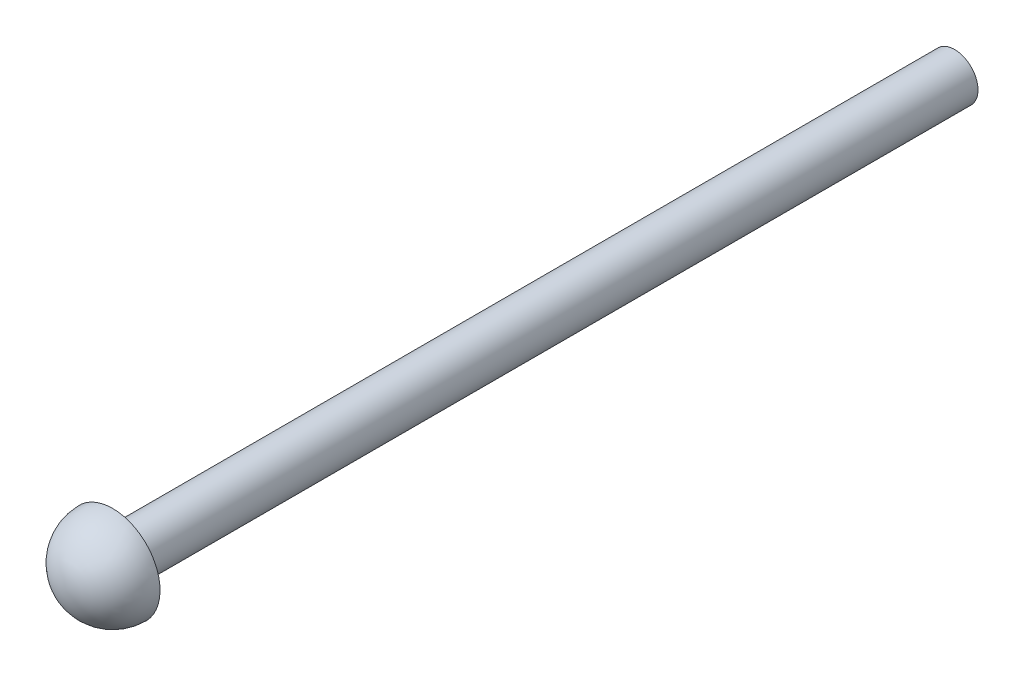
from build123d import *

# Parameters (mm, degrees)
SKETCH1_R           = 3.175
BOSS_EXTRUDE1_DEPTH = 114.3


with BuildPart() as part:
    # Sketch1 → Boss-Extrude1 (new body)
    with BuildSketch(Plane.XY):
        Circle(SKETCH1_R)
    extrude(amount=BOSS_EXTRUDE1_DEPTH)

    # Sketch3 one side → Revolve1 (revolve)
    with BuildSketch(Plane(origin=(0, 0, 0), x_dir=(0, 0, -1), z_dir=(1, 0, 0))):
        with BuildLine():
            ThreePointArc((-120.7135, -0.0635), (-118.835029341, -4.598529341), (-114.3, -6.477))
            Line((-114.3, -6.477), (-114.3, -0.0635))
            Line((-114.3, -0.0635), (-120.7135, -0.0635))
        make_face()
    revolve(axis=Axis((0, -0.0635, 114.3), (0, 0, 1)))


solid = part.part
